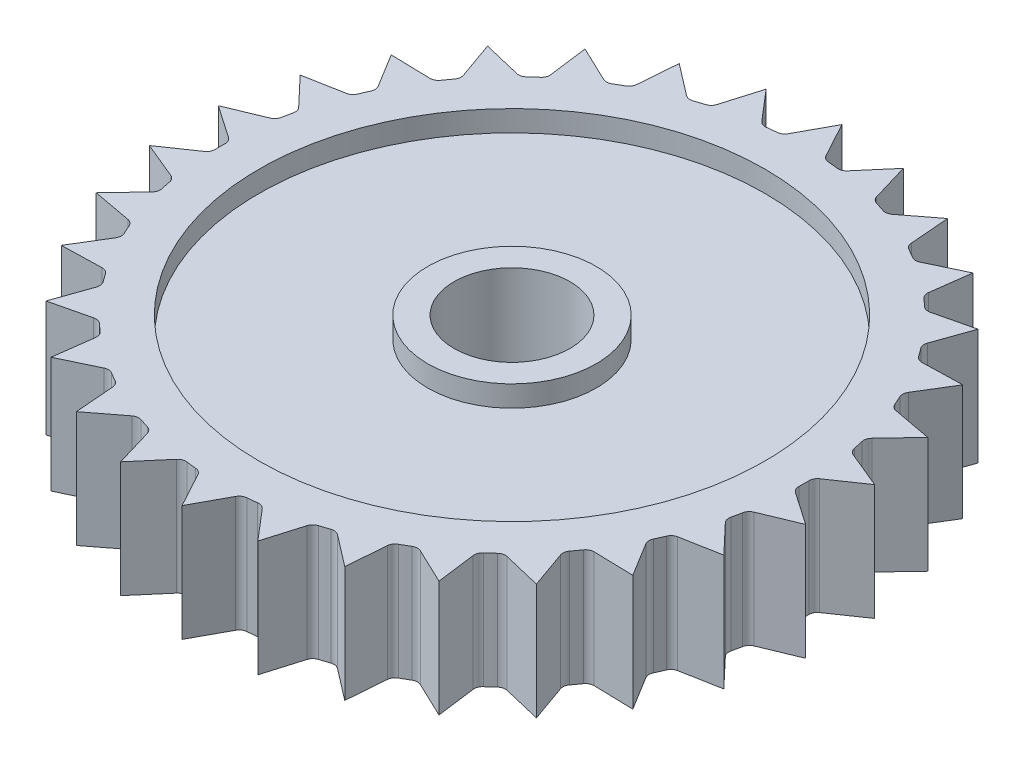
from build123d import *

# Parameters (mm, degrees)
BOSS_EXTRUDE1_DEPTH = 5.5
SKETCH2_R           = 2.75
CUT_EXTRUDE1_DEPTH  = 23.753686902
SKETCH2_3_R         = 12
SKETCH2_3_R_2       = 4
CUT_EXTRUDE2_DEPTH  = 1
CUT_EXTRUDE3_START  = -1
SKETCH3_R           = 12
SKETCH3_R_2         = 4
CUT_EXTRUDE3_DEPTH  = 1


with BuildPart() as part:
    # Sketch1 → Boss-Extrude1 (new body)
    with BuildSketch(Plane(origin=(0, 0, 0), x_dir=(1, 0, 0), z_dir=(0, 1, 0))):
        with BuildLine():
            Line((0, 15.655), (-0.896544703, 14.004328284))
            ThreePointArc((-0.896544703, 14.004328284), (-1.028679328, 13.860758553), (-1.213011653, 13.796778708))
            ThreePointArc((-1.213011653, 13.796778708), (-1.447719216, 13.774128251), (-1.682007151, 13.747485295))
            ThreePointArc((-1.682007151, 13.747485295), (-1.87561353, 13.771742181), (-2.034710522, 13.884702236))
            Line((-2.034710522, 13.884702236), (-3.25485752, 15.312900689))
            Line((-3.25485752, 15.312900689), (-3.788616622, 13.511897985))
            ThreePointArc((-3.788616622, 13.511897985), (-3.888013963, 13.343993265), (-4.055016027, 13.243086688))
            ThreePointArc((-4.055016027, 13.243086688), (-4.279885372, 13.172132751), (-4.503514172, 13.097360807))
            ThreePointArc((-4.503514172, 13.097360807), (-4.697933077, 13.080834592), (-4.877039134, 13.158248074))
            Line((-4.877039134, 13.158248074), (-6.367462147, 14.301554139))
            Line((-6.367462147, 14.301554139), (-6.515107816, 12.428932908))
            ThreePointArc((-6.515107816, 12.428932908), (-6.577423732, 12.244031439), (-6.719796743, 12.110608231))
            ThreePointArc((-6.719796743, 12.110608231), (-6.925, 11.994451842), (-7.128196012, 11.874818803))
            ThreePointArc((-7.128196012, 11.874818803), (-7.314930405, 11.818231762), (-7.506217732, 11.856715331))
            Line((-7.506217732, 11.856715331), (-9.201778125, 12.665161047))
            Line((-9.201778125, 12.665161047), (-8.956857534, 10.802763822))
            ThreePointArc((-8.956857534, 10.802763822), (-8.979368521, 10.608946686), (-9.090890096, 10.448838082))
            ThreePointArc((-9.090890096, 10.448838082), (-9.267458898, 10.292555833), (-9.441341483, 10.133290236))
            ThreePointArc((-9.441341483, 10.133290236), (-9.612230173, 10.039115495), (-9.807338597, 10.036987233))
            Line((-9.807338597, 10.036987233), (-11.633932243, 10.475239643))
            Line((-11.633932243, 10.475239643), (-11.007149599, 8.704462119))
            ThreePointArc((-11.007149599, 8.704462119), (-10.988871818, 8.510200056), (-11.064667928, 8.33040357))
            ThreePointArc((-11.064667928, 8.33040357), (-11.204885372, 8.140825744), (-11.341855025, 7.948888261))
            ThreePointArc((-11.341855025, 7.948888261), (-11.489429359, 7.821241707), (-11.679831705, 7.77859463))
            Line((-11.679831705, 7.77859463), (-13.557627696, 7.8275))
            Line((-13.557627696, 7.8275), (-12.576376408, 6.225733653))
            ThreePointArc((-12.576376408, 6.225733653), (-12.518108686, 6.039516846), (-12.554866678, 5.847890448))
            ThreePointArc((-12.554866678, 5.847890448), (-12.652604588, 5.633302507), (-12.746675079, 5.417081725))
            ThreePointArc((-12.746675079, 5.417081725), (-12.864485349, 5.261542126), (-13.041860121, 5.180240116))
            Line((-13.041860121, 5.180240116), (-14.888789763, 4.837661047))
            Line((-14.888789763, 4.837661047), (-13.59595522, 3.474910753))
            ThreePointArc((-13.59595522, 3.474910753), (-13.500244137, 3.30487777), (-13.49635751, 3.109796452))
            ThreePointArc((-13.49635751, 3.109796452), (-13.54734427, 2.879576918), (-13.594404267, 2.648522725))
            ThreePointArc((-13.594404267, 2.648522725), (-13.677301598, 2.471887906), (-13.833896668, 2.355484252))
            Line((-13.833896668, 2.355484252), (-15.569240272, 1.636393092))
            Line((-15.569240272, 1.636393092), (-14.021325548, 0.572217577))
            ThreePointArc((-14.021325548, 0.572217577), (-13.892354137, 0.425799676), (-13.847992755, 0.235789428))
            ThreePointArc((-13.847992755, 0.235789428), (-13.85, 0), (-13.847992755, -0.235789428))
            ThreePointArc((-13.847992755, -0.235789428), (-13.892354137, -0.425799676), (-14.021325548, -0.572217577))
            Line((-14.021325548, -0.572217577), (-15.569240272, -1.636393092))
            Line((-15.569240272, -1.636393092), (-13.833896668, -2.355484252))
            ThreePointArc((-13.833896668, -2.355484252), (-13.677301598, -2.471887906), (-13.594404267, -2.648522725))
            ThreePointArc((-13.594404267, -2.648522725), (-13.54734427, -2.879576918), (-13.49635751, -3.109796452))
            ThreePointArc((-13.49635751, -3.109796452), (-13.500244137, -3.30487777), (-13.59595522, -3.474910753))
            Line((-13.59595522, -3.474910753), (-14.888789763, -4.837661047))
            Line((-14.888789763, -4.837661047), (-13.041860121, -5.180240116))
            ThreePointArc((-13.041860121, -5.180240116), (-12.864485349, -5.261542126), (-12.746675079, -5.417081725))
            ThreePointArc((-12.746675079, -5.417081725), (-12.652604588, -5.633302507), (-12.554866678, -5.847890448))
            ThreePointArc((-12.554866678, -5.847890448), (-12.518108686, -6.039516846), (-12.576376408, -6.225733653))
            Line((-12.576376408, -6.225733653), (-13.557627696, -7.8275))
            Line((-13.557627696, -7.8275), (-11.679831705, -7.77859463))
            ThreePointArc((-11.679831705, -7.77859463), (-11.489429359, -7.821241707), (-11.341855025, -7.948888261))
            ThreePointArc((-11.341855025, -7.948888261), (-11.204885372, -8.140825744), (-11.064667928, -8.33040357))
            ThreePointArc((-11.064667928, -8.33040357), (-10.988871818, -8.510200056), (-11.007149599, -8.704462119))
            Line((-11.007149599, -8.704462119), (-11.633932243, -10.475239643))
            Line((-11.633932243, -10.475239643), (-9.807338597, -10.036987233))
            ThreePointArc((-9.807338597, -10.036987233), (-9.612230173, -10.039115495), (-9.441341483, -10.133290236))
            ThreePointArc((-9.441341483, -10.133290236), (-9.267458898, -10.292555833), (-9.090890096, -10.448838082))
            ThreePointArc((-9.090890096, -10.448838082), (-8.979368521, -10.608946686), (-8.956857534, -10.802763822))
            Line((-8.956857534, -10.802763822), (-9.201778125, -12.665161047))
            Line((-9.201778125, -12.665161047), (-7.506217732, -11.856715331))
            ThreePointArc((-7.506217732, -11.856715331), (-7.314930405, -11.818231762), (-7.128196012, -11.874818803))
            ThreePointArc((-7.128196012, -11.874818803), (-6.925, -11.994451842), (-6.719796743, -12.110608231))
            ThreePointArc((-6.719796743, -12.110608231), (-6.577423732, -12.244031439), (-6.515107816, -12.428932908))
            Line((-6.515107816, -12.428932908), (-6.367462147, -14.301554139))
            Line((-6.367462147, -14.301554139), (-4.877039134, -13.158248074))
            ThreePointArc((-4.877039134, -13.158248074), (-4.697933077, -13.080834592), (-4.503514172, -13.097360807))
            ThreePointArc((-4.503514172, -13.097360807), (-4.279885372, -13.172132751), (-4.055016027, -13.243086688))
            ThreePointArc((-4.055016027, -13.243086688), (-3.888013963, -13.343993265), (-3.788616622, -13.511897985))
            Line((-3.788616622, -13.511897985), (-3.25485752, -15.312900689))
            Line((-3.25485752, -15.312900689), (-2.034710522, -13.884702236))
            ThreePointArc((-2.034710522, -13.884702236), (-1.87561353, -13.771742181), (-1.682007151, -13.747485295))
            ThreePointArc((-1.682007151, -13.747485295), (-1.447719216, -13.774128251), (-1.213011653, -13.796778708))
            ThreePointArc((-1.213011653, -13.796778708), (-1.028679328, -13.860758553), (-0.896544703, -14.004328284))
            Line((-0.896544703, -14.004328284), (0, -15.655))
            Line((0, -15.655), (0.896544703, -14.004328284))
            ThreePointArc((0.896544703, -14.004328284), (1.028679328, -13.860758553), (1.213011653, -13.796778708))
            ThreePointArc((1.213011653, -13.796778708), (1.447719216, -13.774128251), (1.682007151, -13.747485295))
            ThreePointArc((1.682007151, -13.747485295), (1.87561353, -13.771742181), (2.034710522, -13.884702236))
            Line((2.034710522, -13.884702236), (3.25485752, -15.312900689))
            Line((3.25485752, -15.312900689), (3.788616622, -13.511897985))
            ThreePointArc((3.788616622, -13.511897985), (3.888013963, -13.343993265), (4.055016027, -13.243086688))
            ThreePointArc((4.055016027, -13.243086688), (4.279885372, -13.172132751), (4.503514172, -13.097360807))
            ThreePointArc((4.503514172, -13.097360807), (4.697933077, -13.080834592), (4.877039134, -13.158248074))
            Line((4.877039134, -13.158248074), (6.367462147, -14.301554139))
            Line((6.367462147, -14.301554139), (6.515107816, -12.428932908))
            ThreePointArc((6.515107816, -12.428932908), (6.577423732, -12.244031439), (6.719796743, -12.110608231))
            ThreePointArc((6.719796743, -12.110608231), (6.925, -11.994451842), (7.128196012, -11.874818803))
            ThreePointArc((7.128196012, -11.874818803), (7.314930405, -11.818231762), (7.506217732, -11.856715331))
            Line((7.506217732, -11.856715331), (9.201778125, -12.665161047))
            Line((9.201778125, -12.665161047), (8.956857534, -10.802763822))
            ThreePointArc((8.956857534, -10.802763822), (8.979368521, -10.608946686), (9.090890096, -10.448838082))
            ThreePointArc((9.090890096, -10.448838082), (9.267458898, -10.292555833), (9.441341483, -10.133290236))
            ThreePointArc((9.441341483, -10.133290236), (9.612230173, -10.039115495), (9.807338597, -10.036987233))
            Line((9.807338597, -10.036987233), (11.633932243, -10.475239643))
            Line((11.633932243, -10.475239643), (11.007149599, -8.704462119))
            ThreePointArc((11.007149599, -8.704462119), (10.988871818, -8.510200056), (11.064667928, -8.33040357))
            ThreePointArc((11.064667928, -8.33040357), (11.204885372, -8.140825744), (11.341855025, -7.948888261))
            ThreePointArc((11.341855025, -7.948888261), (11.489429359, -7.821241707), (11.679831705, -7.77859463))
            Line((11.679831705, -7.77859463), (13.557627696, -7.8275))
            Line((13.557627696, -7.8275), (12.576376408, -6.225733653))
            ThreePointArc((12.576376408, -6.225733653), (12.518108686, -6.039516846), (12.554866678, -5.847890448))
            ThreePointArc((12.554866678, -5.847890448), (12.652604588, -5.633302507), (12.746675079, -5.417081725))
            ThreePointArc((12.746675079, -5.417081725), (12.864485349, -5.261542126), (13.041860121, -5.180240116))
            Line((13.041860121, -5.180240116), (14.888789763, -4.837661047))
            Line((14.888789763, -4.837661047), (13.59595522, -3.474910753))
            ThreePointArc((13.59595522, -3.474910753), (13.500244137, -3.30487777), (13.49635751, -3.109796452))
            ThreePointArc((13.49635751, -3.109796452), (13.54734427, -2.879576918), (13.594404267, -2.648522725))
            ThreePointArc((13.594404267, -2.648522725), (13.677301598, -2.471887906), (13.833896668, -2.355484252))
            Line((13.833896668, -2.355484252), (15.569240272, -1.636393092))
            Line((15.569240272, -1.636393092), (14.021325548, -0.572217577))
            ThreePointArc((14.021325548, -0.572217577), (13.892354137, -0.425799676), (13.847992755, -0.235789428))
            ThreePointArc((13.847992755, -0.235789428), (13.85, 0), (13.847992755, 0.235789428))
            ThreePointArc((13.847992755, 0.235789428), (13.892354137, 0.425799676), (14.021325548, 0.572217577))
            Line((14.021325548, 0.572217577), (15.569240272, 1.636393092))
            Line((15.569240272, 1.636393092), (13.833896668, 2.355484252))
            ThreePointArc((13.833896668, 2.355484252), (13.677301598, 2.471887906), (13.594404267, 2.648522725))
            ThreePointArc((13.594404267, 2.648522725), (13.54734427, 2.879576918), (13.49635751, 3.109796452))
            ThreePointArc((13.49635751, 3.109796452), (13.500244137, 3.30487777), (13.59595522, 3.474910753))
            Line((13.59595522, 3.474910753), (14.888789763, 4.837661047))
            Line((14.888789763, 4.837661047), (13.041860121, 5.180240116))
            ThreePointArc((13.041860121, 5.180240116), (12.864485349, 5.261542126), (12.746675079, 5.417081725))
            ThreePointArc((12.746675079, 5.417081725), (12.652604588, 5.633302507), (12.554866678, 5.847890448))
            ThreePointArc((12.554866678, 5.847890448), (12.518108686, 6.039516846), (12.576376408, 6.225733653))
            Line((12.576376408, 6.225733653), (13.557627696, 7.8275))
            Line((13.557627696, 7.8275), (11.679831705, 7.77859463))
            ThreePointArc((11.679831705, 7.77859463), (11.489429359, 7.821241707), (11.341855025, 7.948888261))
            ThreePointArc((11.341855025, 7.948888261), (11.204885372, 8.140825744), (11.064667928, 8.33040357))
            ThreePointArc((11.064667928, 8.33040357), (10.988871818, 8.510200056), (11.007149599, 8.704462119))
            Line((11.007149599, 8.704462119), (11.633932243, 10.475239643))
            Line((11.633932243, 10.475239643), (9.807338597, 10.036987233))
            ThreePointArc((9.807338597, 10.036987233), (9.612230173, 10.039115495), (9.441341483, 10.133290236))
            ThreePointArc((9.441341483, 10.133290236), (9.267458898, 10.292555833), (9.090890096, 10.448838082))
            ThreePointArc((9.090890096, 10.448838082), (8.979368521, 10.608946686), (8.956857534, 10.802763822))
            Line((8.956857534, 10.802763822), (9.201778125, 12.665161047))
            Line((9.201778125, 12.665161047), (7.506217732, 11.856715331))
            ThreePointArc((7.506217732, 11.856715331), (7.314930405, 11.818231762), (7.128196012, 11.874818803))
            ThreePointArc((7.128196012, 11.874818803), (6.925, 11.994451842), (6.719796743, 12.110608231))
            ThreePointArc((6.719796743, 12.110608231), (6.577423732, 12.244031439), (6.515107816, 12.428932908))
            Line((6.515107816, 12.428932908), (6.367462147, 14.301554139))
            Line((6.367462147, 14.301554139), (4.877039134, 13.158248074))
            ThreePointArc((4.877039134, 13.158248074), (4.697933077, 13.080834592), (4.503514172, 13.097360807))
            ThreePointArc((4.503514172, 13.097360807), (4.279885372, 13.172132751), (4.055016027, 13.243086688))
            ThreePointArc((4.055016027, 13.243086688), (3.888013963, 13.343993265), (3.788616622, 13.511897985))
            Line((3.788616622, 13.511897985), (3.25485752, 15.312900689))
            Line((3.25485752, 15.312900689), (2.034710522, 13.884702236))
            ThreePointArc((2.034710522, 13.884702236), (1.87561353, 13.771742181), (1.682007151, 13.747485295))
            ThreePointArc((1.682007151, 13.747485295), (1.447719216, 13.774128251), (1.213011653, 13.796778708))
            ThreePointArc((1.213011653, 13.796778708), (1.028679328, 13.860758553), (0.896544703, 14.004328284))
            Line((0.896544703, 14.004328284), (0, 15.655))
        make_face()
    extrude(amount=BOSS_EXTRUDE1_DEPTH)

    # Sketch2 → Cut-Extrude1 (cut, through all)
    with BuildSketch(Plane(origin=(0, 5.5, 0), x_dir=(1, 0, 0), z_dir=(0, 1, 0))):
        Circle(SKETCH2_R)
    extrude(amount=-CUT_EXTRUDE1_DEPTH, mode=Mode.SUBTRACT)

    # Sketch2_3 → Cut-Extrude2 (cut)
    with BuildSketch(Plane(origin=(0, 5.5, 0), x_dir=(1, 0, 0), z_dir=(0, 1, 0))):
        Circle(SKETCH2_3_R)
        Circle(SKETCH2_3_R_2, mode=Mode.SUBTRACT)
    extrude(amount=-CUT_EXTRUDE2_DEPTH, mode=Mode.SUBTRACT)

    # Sketch3 → Cut-Extrude3 (cut)
    with BuildSketch(Plane.XZ.offset(CUT_EXTRUDE3_START)):
        Circle(SKETCH3_R)
        Circle(SKETCH3_R_2, mode=Mode.SUBTRACT)
    extrude(amount=CUT_EXTRUDE3_DEPTH, mode=Mode.SUBTRACT)


solid = part.part
